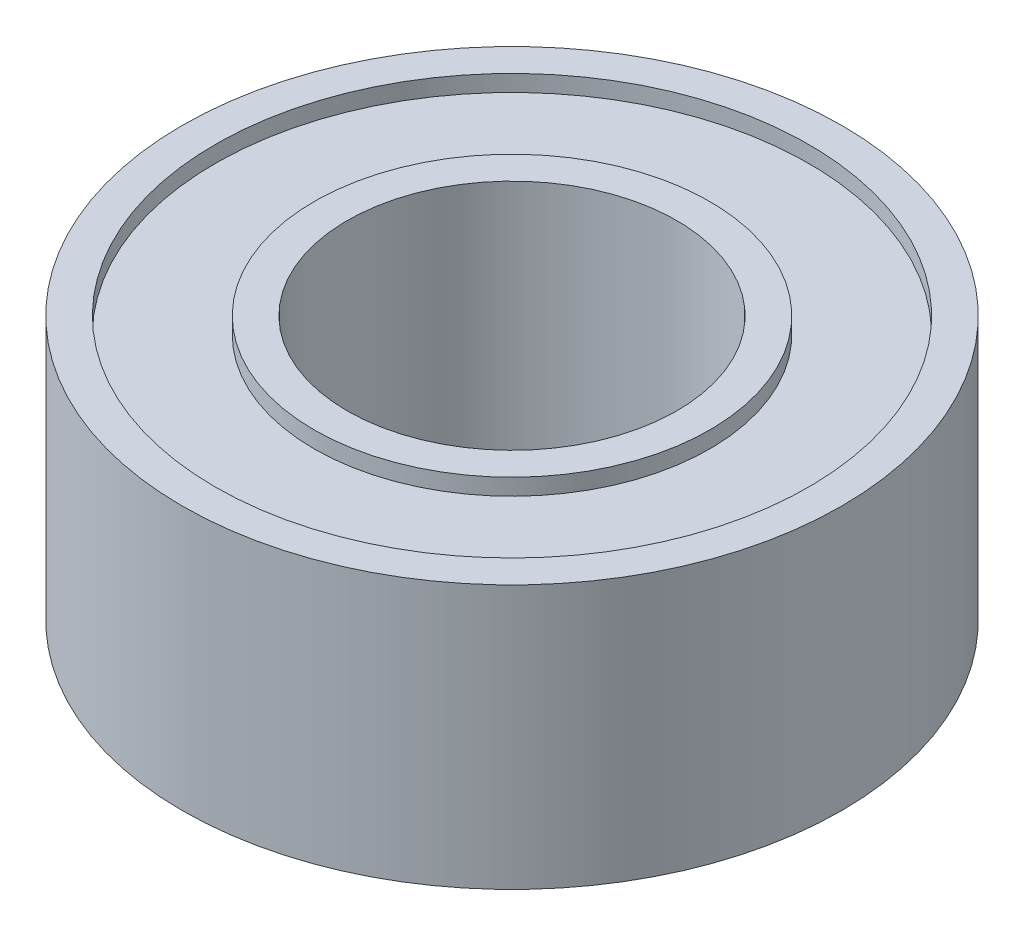
from build123d import *

# Parameters (mm, degrees)
SKETCH1_R           = 5
SKETCH1_R_2         = 2.5
BOSS_EXTRUDE1_DEPTH = 2
SKETCH2_R           = 4.5
SKETCH2_R_2         = 3
CUT_EXTRUDE1_DEPTH  = 0.25


with BuildPart() as part:
    # Sketch1 → Boss-Extrude1 (new body, symmetric)
    with BuildSketch(Plane(origin=(0, 0, 0), x_dir=(1, 0, 0), z_dir=(0, 1, 0))):
        Circle(SKETCH1_R)
        Circle(SKETCH1_R_2, mode=Mode.SUBTRACT)
    extrude(amount=BOSS_EXTRUDE1_DEPTH, both=True)

    # Sketch2 → Cut-Extrude1 (cut)
    with BuildSketch(Plane(origin=(0, 2, 0), x_dir=(1, 0, 0), z_dir=(0, 1, 0))):
        Circle(SKETCH2_R)
        Circle(SKETCH2_R_2, mode=Mode.SUBTRACT)
    cut_extrude1 = extrude(amount=-CUT_EXTRUDE1_DEPTH, mode=Mode.SUBTRACT)

    # Mirror1: Cut-Extrude1 across plane
    add(cut_extrude1.mirror(Plane.ZX), mode=Mode.SUBTRACT)


solid = part.part
